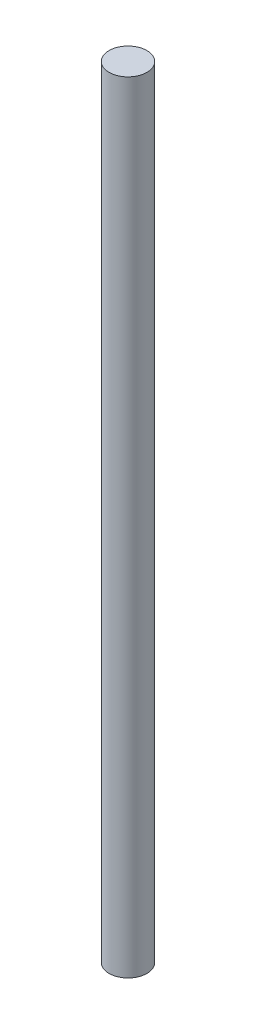
from build123d import *

# Parameters (mm, degrees)
SKETCH2_R           = 1.6
BOSS_EXTRUDE1_DEPTH = 66


with BuildPart() as part:
    # Sketch2 → Boss-Extrude1 (new body)
    with BuildSketch(Plane(origin=(0, 0, 0), x_dir=(1, 0, 0), z_dir=(0, 1, 0))):
        Circle(SKETCH2_R)
    extrude(amount=BOSS_EXTRUDE1_DEPTH)


solid = part.part
